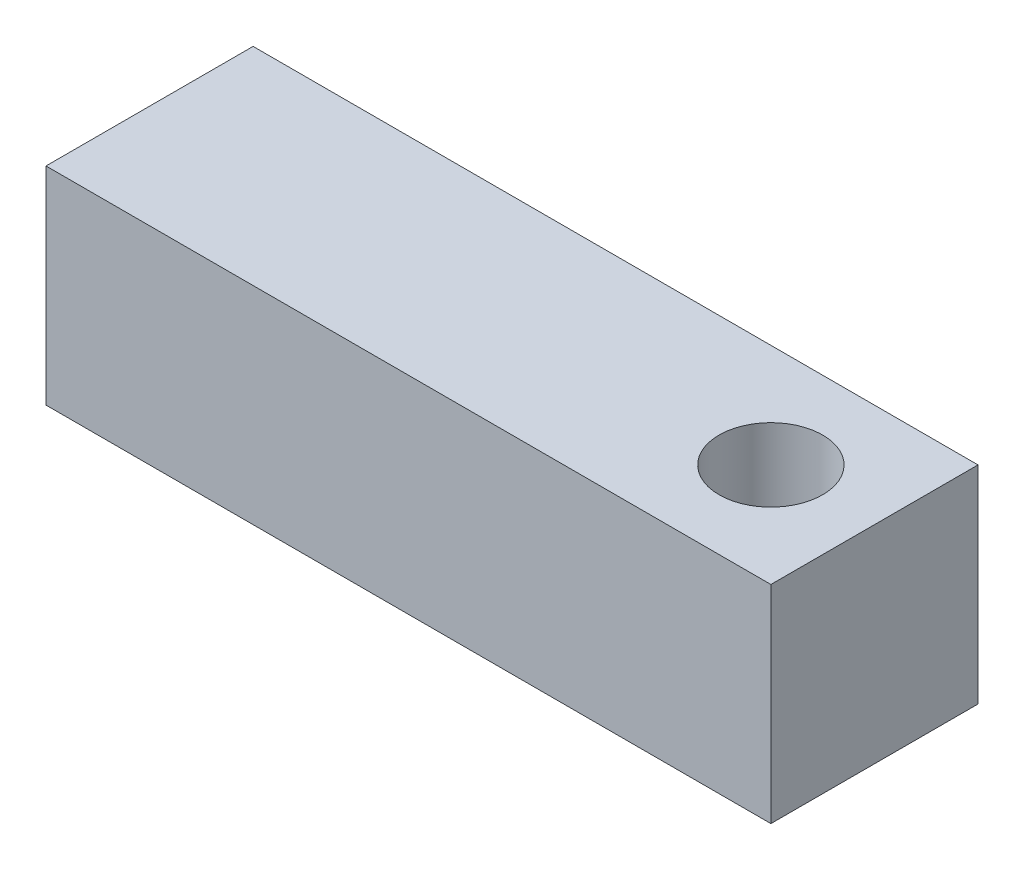
from build123d import *

# Parameters (mm, degrees)
SKETCH1_W           = 88.9
SKETCH1_H           = 25.4
SKETCH1_R           = 6.35
BOSS_EXTRUDE1_DEPTH = 25.4


with BuildPart() as part:
    # Sketch1 → Boss-Extrude1 (new body)
    with BuildSketch(Plane(origin=(0, 0, 0), x_dir=(1, 0, 0), z_dir=(0, 1, 0))):
        with Locations((29.989485536, 12.7)):
            Rectangle(SKETCH1_W, SKETCH1_H)
        with Locations((61.739485536, 12.7)):
            Circle(SKETCH1_R, mode=Mode.SUBTRACT)
    extrude(amount=BOSS_EXTRUDE1_DEPTH)


solid = part.part
